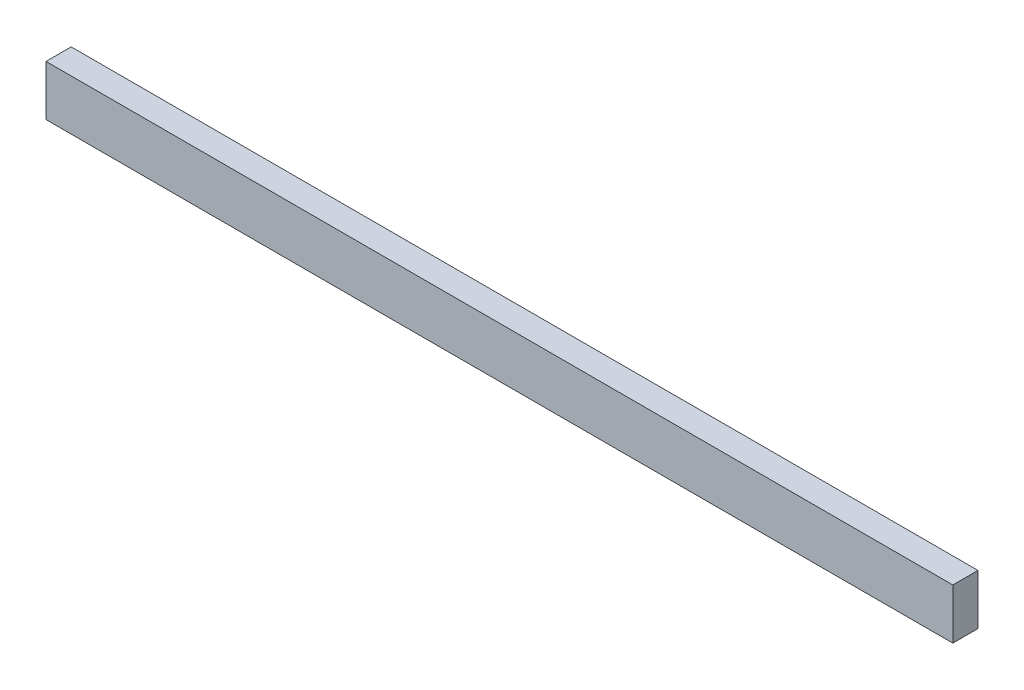
from build123d import *

# Parameters (mm, degrees)
SKETCH1_W           = 360
SKETCH1_H           = 20
BOSS_EXTRUDE1_DEPTH = 10


with BuildPart() as part:
    # Sketch1 → Boss-Extrude1 (new body)
    with BuildSketch(Plane.XY):
        with Locations((-29.698189135, 40.477867203)):
            Rectangle(SKETCH1_W, SKETCH1_H)
    extrude(amount=BOSS_EXTRUDE1_DEPTH)


solid = part.part
